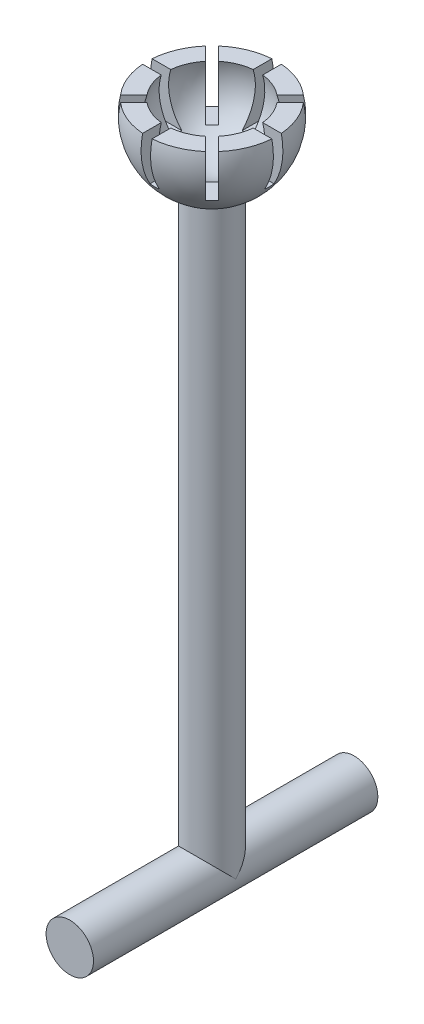
from build123d import *

# Parameters (mm, degrees)
ESQUISSE4_W                  = 1
ESQUISSE4_H                  = 15
ENL_V_MAT_EXTRU_2_DEPTH      = 5
R_P_TITION_CIRCULAIRE1_COUNT = 4
R_P_TITION_CIRCULAIRE1_ANGLE = 135
ESQUISSE5_R                  = 2.5
BOSS_EXTRU_1_DEPTH           = 57
ESQUISSE6_R                  = 2.5
BOSS_EXTRU_2_DEPTH           = 15


with BuildPart() as part:
    # Esquisse1 → R_volution1 (revolve)
    with BuildSketch(Plane.XY, mode=Mode.PRIVATE) as r_volution1_sk:
        with BuildLine():
            Line((-4.874423043, 1.5), (-6.837397166, 1.5))
            ThreePointArc((-6.837397166, 1.5), (-6.160398345, -3.324077651), (-2.5, -6.538348415))
            Line((-2.5, -6.538348415), (-2.5, -11.538348415))
            Line((-2.5, -11.538348415), (0, -11.538348415))
            Line((0, -11.538348415), (0, -5.1))
            ThreePointArc((0, -5.1), (-4.102438299, -3.029851482), (-4.874423043, 1.5))
        make_face()
    revolve(r_volution1_sk.sketch.rotate(Axis((0, -11.538348415, 0), (0, 1, 0)), 270), axis=Axis((0, -11.538348415, 0), (0, 1, 0)))  # turned: the seam where the file's is

    # Esquisse4 → Enl_v. mat.-Extru.2 (cut)
    with BuildSketch(Plane(origin=(0, 1.5, 0), x_dir=(1, 0, 0), z_dir=(0, 1, 0))):
        Rectangle(ESQUISSE4_W, ESQUISSE4_H)
    enl_v_mat_extru_2 = extrude(amount=-ENL_V_MAT_EXTRU_2_DEPTH, mode=Mode.SUBTRACT)

    # R_p_tition circulaire1: Enl_v. mat.-Extru.2 ×4 about axis
    r_p_tition_circulaire1_axis = Axis((0, 0, 0), (0, -1, 0))
    for i in range(1, R_P_TITION_CIRCULAIRE1_COUNT):
        add(enl_v_mat_extru_2.rotate(r_p_tition_circulaire1_axis, i * R_P_TITION_CIRCULAIRE1_ANGLE / (R_P_TITION_CIRCULAIRE1_COUNT - 1)), mode=Mode.SUBTRACT)

    # Esquisse5 → Boss.-Extru.1 (add)
    with BuildSketch(Plane.XZ.offset(11.538348415)):
        with Locations(Location((0, 0, 0), (0, 0, 270))):  # turned: the seam where the file's is
            Circle(ESQUISSE5_R)
    extrude(amount=BOSS_EXTRU_1_DEPTH)

    # Esquisse6 → Boss.-Extru.2 (add, symmetric)
    with BuildSketch(Plane.XY):
        with Locations((0, -68.538348415)):
            Circle(ESQUISSE6_R)
    extrude(amount=BOSS_EXTRU_2_DEPTH, both=True)


solid = part.part
